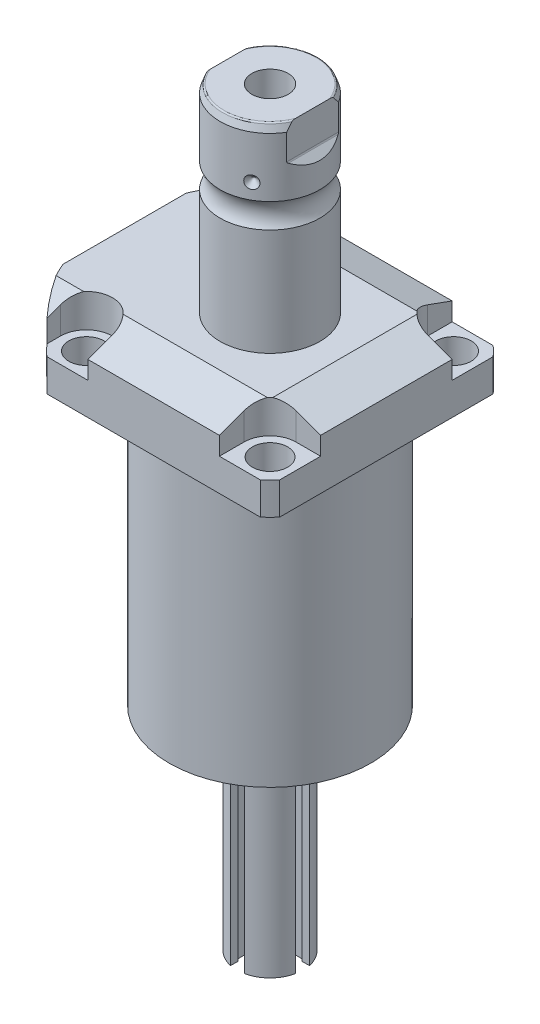
from build123d import *

# Parameters (mm, degrees)
SKETCH1_W                   = 88.9
SKETCH1_H                   = 99.9998
EXTRUDE1_DEPTH              = 129.794
SKETCH2_OUTSIDE_W           = 139.282
SKETCH2_OUTSIDE_H           = 128.182
SKETCH2_OUTSIDE_R           = 60.325
CUT_EXTRUDE1_DEPTH          = 130.794
SKETCH3_W                   = 38.1
SKETCH3_H                   = 104.775
FILLET1_R                   = 0.381
CUT_EXTRUDE2_DEPTH          = 12.7
CUT_EXTRUDE9_START          = -56.5498
CUT_EXTRUDE9_DEPTH          = 101.9998
CUT_EXTRUDE7_DEPTH          = 45.45
CUT_EXTRUDE7_DEPTH_BACK     = 45.45
SKETCH10_R                  = 1.1811
SKETCH11_R                  = 1.1811
CUT_EXTRUDE8_DEPTH          = 53.34
SKETCH17_W                  = 6.7437
SKETCH17_H                  = 12.319
HOLE1_AT_2_COUNT            = 2
HOLE1_AT_2_PITCH            = 70.104
HOLE1_AT_3_COUNT            = 2
HOLE1_AT_3_PITCH            = 99.142027577
HOLE1_AT_4_COUNT            = 2
HOLE1_AT_4_PITCH            = 70.104
CHAMFER1_SIZE               = 0.635
FILLET2_R                   = 0.635
CIRPATTERN1_COUNT           = 3
SKETCH24_R                  = 1.7272
CUT_EXTRUDE10_DEPTH         = 2.54
SKETCH25_R                  = 2.7051
EXTRUDE2_DEPTH              = 2.9464
CUT_EXTRUDE11_DEPTH         = 6.477
SKETCH32_W                  = 6.985
SKETCH32_H                  = 70.612
CUT_EXTRUDE12_DEPTH         = 3.302
CUT_EXTRUDE13_DEPTH         = 2.032
CIRPATTERN2_COUNT           = 2
CIRPATTERN2_ANGLE           = 90
CIRPATTERN2_COPY_1_DEPTH    = 6.477
CIRPATTERN2_COPY_2_SKETCH_W = 6.985
CIRPATTERN2_COPY_2_SKETCH_H = 70.612
CIRPATTERN2_COPY_2_DEPTH    = 3.302


with BuildPart() as part:
    # Sketch1 → Extrude1 (new body)
    with BuildSketch(Plane.ZX):
        with Locations((0, -5.5499)):
            Rectangle(SKETCH1_W, SKETCH1_H)
    extrude(amount=EXTRUDE1_DEPTH)

    # Sketch2 outside → Cut-Extrude1 (cut, through all)
    with BuildSketch(Plane.XZ):
        with Locations((-5.55, 0)):
            Rectangle(SKETCH2_OUTSIDE_W, SKETCH2_OUTSIDE_H)
        Circle(SKETCH2_OUTSIDE_R, mode=Mode.SUBTRACT)
    extrude(amount=-CUT_EXTRUDE1_DEPTH, mode=Mode.SUBTRACT)

    # Sketch3 → Cut-Revolve1 (revolve, cut)
    with BuildSketch(Plane(origin=(0, 0, 0), x_dir=(0, 0, 1), z_dir=(1, 0, 0))):
        with Locations((57.5437, -52.3875)):
            Rectangle(SKETCH3_W, SKETCH3_H)
    revolve(axis=Axis((0, 93.345, 0), (0, -1, 0)), mode=Mode.SUBTRACT)

    # Fillet1
    fillet1_edges = [part.edges().sort_by_distance(p)[0] for p in [
        (0, 104.775, -38.4937),
    ]]
    fillet(fillet1_edges, radius=FILLET1_R)

    # Sketch4 → Cut-Extrude2 (cut)
    with BuildSketch(Plane(origin=(0, 129.794, 0), x_dir=(-1, 0, 0), z_dir=(0, 1, 0))):
        with BuildLine():
            Line((-25.1206, -44.45), (-25.1206, -35.052))
            ThreePointArc((-25.1206, -35.052), (-28.029439713, -28.029439713), (-35.052, -25.1206))
            Line((-35.052, -25.1206), (-44.45, -25.1206))
            Line((-44.45, -25.1206), (-44.45, -44.45))
            Line((-44.45, -44.45), (-25.1206, -44.45))
        make_face()
        with BuildLine():
            Line((44.9834, -44.45), (25.1206, -44.45))
            Line((25.1206, -44.45), (25.1206, -35.052))
            ThreePointArc((25.1206, -35.052), (35.052, -25.1206), (44.9834, -35.052))
            Line((44.9834, -35.052), (44.9834, -44.45))
        make_face()
        with BuildLine():
            Line((25.1206, 44.45), (25.1206, 35.052))
            ThreePointArc((25.1206, 35.052), (35.052, 25.1206), (44.9834, 35.052))
            Line((44.9834, 35.052), (44.9834, 44.45))
            Line((44.9834, 44.45), (25.1206, 44.45))
        make_face()
        with BuildLine():
            Line((-35.052, 25.1206), (-44.45, 25.1206))
            Line((-44.45, 25.1206), (-44.45, 44.45))
            Line((-44.45, 44.45), (-25.1206, 44.45))
            Line((-25.1206, 44.45), (-25.1206, 35.052))
            ThreePointArc((-25.1206, 35.052), (-28.029439713, 28.029439713), (-35.052, 25.1206))
        make_face()
    extrude(amount=-CUT_EXTRUDE2_DEPTH, mode=Mode.SUBTRACT)

    # Sketch5 → Cut-Extrude9 (cut)
    with BuildSketch(Plane(origin=(0, 0, 0), x_dir=(0, 0, -1), z_dir=(1, 0, 0)).offset(CUT_EXTRUDE9_START)):
        Polygon((-28.575, 129.794), (-44.45, 124.015972531), (-44.45, 129.794), align=None)
    cut_extrude9 = extrude(amount=CUT_EXTRUDE9_DEPTH, mode=Mode.SUBTRACT)

    # Mirror1: Cut-Extrude9 across plane
    add(cut_extrude9.mirror(Plane.XY), mode=Mode.SUBTRACT)

    # Sketch9 → Cut-Extrude7 (cut, two sides)
    with BuildSketch(Plane.XY) as cut_extrude7_sk:
        Polygon((28.575, 129.794), (44.45, 124.015972531), (44.45, 129.794), align=None)
    extrude(amount=CUT_EXTRUDE7_DEPTH, mode=Mode.SUBTRACT)
    extrude(cut_extrude7_sk.sketch, amount=-CUT_EXTRUDE7_DEPTH_BACK, mode=Mode.SUBTRACT)

    # Sketch20 → Cut-Revolve4 (revolve, cut)
    with BuildSketch(Plane(origin=(-41.402, 88.9, -18.1102), x_dir=(0, 1, 0), z_dir=(1, 0, 0)), mode=Mode.PRIVATE) as cut_revolve4_sk:
        Polygon((15.875, 41.9227), (17.3228, 41.9227), (17.3228, 39.4716), (18.3388, 39.4716), (18.3388, 37.465), (29.3116, 37.465), (29.3116, 36.2204), (15.875, 36.2204), align=None)
    cut_revolve4 = revolve(cut_revolve4_sk.sketch.rotate(Axis((-41.402, 81.620304954, 18.1102), (0, 1, 0)), 180), axis=Axis((-41.402, 81.620304954, 18.1102), (0, 1, 0)), mode=Mode.SUBTRACT)  # turned: the seam where the file's is

    # Mirror10: Cut-Revolve4 across plane
    add(cut_revolve4.mirror(Plane.XY), mode=Mode.SUBTRACT)

    # S2D0007 → Cut-Revolve2 (revolve, cut)
    with BuildSketch(Plane(origin=(-55.5498, 101.9048, 12.9794), x_dir=(0, 1, 0), z_dir=(0, 0, 1)), mode=Mode.PRIVATE) as cut_revolve2_sk:
        Polygon((15.875, 0), (26.3525, 0), (26.3525, -0.254), (22.0599, -0.254), (21.517306865, -2.8067), (20.8534, -3.470606865), (20.8534, -14.224), (15.875, -14.224), align=None)
    revolve(cut_revolve2_sk.sketch.rotate(Axis((944.4502, 117.7798, 12.9794), (-1, 0, 0)), 90), axis=Axis((944.4502, 117.7798, 12.9794), (-1, 0, 0)), mode=Mode.SUBTRACT)  # turned: the seam where the file's is

    # Sketch13 → Cut-Revolve3 (revolve, cut)
    with BuildSketch(Plane(origin=(-55.5498, 101.9048, -12.9794), x_dir=(0, 1, 0), z_dir=(0, 0, 1)), mode=Mode.PRIVATE) as cut_revolve3_sk:
        Polygon((15.875, 0), (26.3525, 0), (26.3525, -0.254), (22.0599, -0.254), (21.517306865, -2.8067), (20.8534, -3.470606865), (20.8534, -14.224), (15.875, -14.224), align=None)
    revolve(cut_revolve3_sk.sketch.rotate(Axis((944.4502, 117.7798, -12.9794), (-1, 0, 0)), 90), axis=Axis((944.4502, 117.7798, -12.9794), (-1, 0, 0)), mode=Mode.SUBTRACT)  # turned: the seam where the file's is

    # Sketch15 → Revolve3 (revolve)
    with BuildSketch(Plane(origin=(0, 0, 0), x_dir=(0, -1, 0), z_dir=(1, 0, 0)), mode=Mode.PRIVATE) as revolve3_sk:
        with BuildLine():
            Line((-129.794, 0), (-129.794, 19.05))
            Line((-129.794, 19.05), (-170.57830643, 19.05))
            ThreePointArc((-170.57830643, 19.05), (-175.2854, 17.5006), (-179.99249357, 19.05))
            Line((-179.99249357, 19.05), (-202.5396, 19.05))
            Line((-202.5396, 19.05), (-205.4606, 17.986842946))
            Line((-205.4606, 17.986842946), (-205.4606, 0))
            Line((-205.4606, 0), (-129.794, 0))
        make_face()
    revolve(revolve3_sk.sketch.rotate(Axis((0, 197.63613, 0), (0, -1, 0)), 180), axis=Axis((0, 197.63613, 0), (0, -1, 0)))  # turned: the seam where the file's is

    # Sketch16 → Cut-Extrude8 (cut, symmetric)
    with BuildSketch(Plane(origin=(0, 0, 0), x_dir=(0, -1, 0), z_dir=(0, 0, -1))):
        with BuildLine():
            Line((-205.4606, 19.05), (-189.676369265, 19.05))
            Line((-189.676369265, 19.05), (-192.221784633, 16.504584633))
            ThreePointArc((-192.221784633, 16.504584633), (-192.468995225, 16.339403796), (-192.7606, 16.2814))
            Line((-192.7606, 16.2814), (-205.4606, 16.2814))
            Line((-205.4606, 16.2814), (-205.4606, 19.05))
        make_face()
        with BuildLine():
            Line((-205.4606, -19.05), (-205.4606, -16.2814))
            Line((-205.4606, -16.2814), (-192.7606, -16.2814))
            ThreePointArc((-192.7606, -16.2814), (-192.468995225, -16.339403796), (-192.221784633, -16.504584633))
            Line((-192.221784633, -16.504584633), (-189.676369265, -19.05))
            Line((-189.676369265, -19.05), (-205.4606, -19.05))
        make_face()
    extrude(amount=CUT_EXTRUDE8_DEPTH, both=True, mode=Mode.SUBTRACT)

    # Sketch17 → Hole1 (revolve, cut)
    with BuildSketch(Plane(origin=(35.052, 117.094, -35.052), x_dir=(0, 0, 1), z_dir=(1, 0, 0))):
        with Locations((3.37185, 6.1595)):
            Rectangle(SKETCH17_W, SKETCH17_H)
    hole1 = revolve(axis=Axis((35.052, 7.094, -35.052), (0, 1, 0)), mode=Mode.SUBTRACT)

    # Hole1 at 2: Hole1 ×2
    with Locations(*[(0, 0, i * HOLE1_AT_2_PITCH) for i in range(1, HOLE1_AT_2_COUNT)]):
        add(hole1, mode=Mode.SUBTRACT)

    # Hole1 at 3: Hole1 ×2
    with Locations(*[Vector(-0.707106781, 0, 0.707106781) * (i * HOLE1_AT_3_PITCH) for i in range(1, HOLE1_AT_3_COUNT)]):
        add(hole1, mode=Mode.SUBTRACT)

    # Hole1 at 4: Hole1 ×2
    with Locations(*[(-i * HOLE1_AT_4_PITCH, 0, 0) for i in range(1, HOLE1_AT_4_COUNT)]):
        add(hole1, mode=Mode.SUBTRACT)

    # Chamfer1
    chamfer1_edges = [part.edges().sort_by_distance(p)[0] for p in [
        (-41.402, 107.2388, 19.3548),
        (-41.402, 107.2388, -19.3548),
    ]]
    chamfer(chamfer1_edges, length=CHAMFER1_SIZE)

    # Sketch21 → Cut-Revolve5 (revolve, cut)
    with BuildSketch(Plane.XY, mode=Mode.PRIVATE) as cut_revolve5_sk:
        Polygon((0, 180.0606), (6.9342, 184.227087704), (6.9342, 205.4606), (0, 205.4606), align=None)
    revolve(cut_revolve5_sk.sketch.rotate(Axis((0, 0, 0), (0, 1, 0)), 270), axis=Axis((0, 0, 0), (0, 1, 0)), mode=Mode.SUBTRACT)  # turned: the seam where the file's is

    # Fillet2
    fillet2_edges = [part.edges().sort_by_distance(p)[0] for p in [
        (0, 205.4606, 17.986842946),
        (0, 205.4606, -17.986842946),
    ]]
    fillet(fillet2_edges, radius=FILLET2_R)

    # Sketch22 → Cut-Revolve6 (revolve, cut)
    with BuildSketch(Plane.XY, mode=Mode.PRIVATE) as cut_revolve6_sk:
        Polygon((-19.05, 188.3664), (-16.637, 185.9534), (-19.05, 185.9534), align=None)
    cut_revolve6 = revolve(cut_revolve6_sk.sketch.rotate(Axis((-37.997376206, 185.9534, 0), (1, 0, 0)), 90), axis=Axis((-37.997376206, 185.9534, 0), (1, 0, 0)), mode=Mode.SUBTRACT)  # turned: the seam where the file's is

    # CirPattern1: Cut-Revolve6 ×3 about axis
    cirpattern1_axis = Axis((0, 197.63613, 0), (0, 1, 0))
    for i in range(1, CIRPATTERN1_COUNT):
        add(cut_revolve6.rotate(cirpattern1_axis, i * 360 / CIRPATTERN1_COUNT), mode=Mode.SUBTRACT)

    # Sketch23 → Revolve5 (revolve)
    with BuildSketch(Plane.XY, mode=Mode.PRIVATE) as revolve5_sk:
        Polygon((0, 0), (22.225, 0), (22.225, -2.54), (12.7, -2.54), (12.7, -81.28), (0, -81.28), align=None)
    revolve(revolve5_sk.sketch.rotate(Axis((0, -1000, 0), (0, 1, 0)), 270), axis=Axis((0, -1000, 0), (0, 1, 0)))  # turned: the seam where the file's is

    # Sketch24 → Cut-Extrude10 (cut)
    with BuildSketch(Plane.XZ.offset(2.54)):
        with Locations((19.431, 0)):
            Circle(SKETCH24_R)
        with Locations((16.827739621, 9.7155)):
            Circle(SKETCH24_R)
        with Locations((9.7155, 16.827739621)):
            Circle(SKETCH24_R)
        with Locations((0, 19.431)):
            Circle(SKETCH24_R)
        with Locations(Location((-9.7155, 16.827739621, 0), (0, 0, 270))):  # turned: the seam where the file's is
            Circle(SKETCH24_R)
        with Locations(Location((-16.827739621, 9.7155, 0), (0, 0, 270))):  # turned: the seam where the file's is
            Circle(SKETCH24_R)
        with Locations(Location((-19.431, 0, 0), (0, 0, 270))):  # turned: the seam where the file's is
            Circle(SKETCH24_R)
        with Locations((-16.827739621, -9.7155)):
            Circle(SKETCH24_R)
        with Locations((-9.7155, -16.827739621)):
            Circle(SKETCH24_R)
        with Locations(Location((0, -19.431, 0), (0, 0, 270))):  # turned: the seam where the file's is
            Circle(SKETCH24_R)
        with Locations(Location((9.7155, -16.827739621, 0), (0, 0, 270))):  # turned: the seam where the file's is
            Circle(SKETCH24_R)
        with Locations(Location((16.827739621, -9.7155, 0), (0, 0, 270))):  # turned: the seam where the file's is
            Circle(SKETCH24_R)
    extrude(amount=-CUT_EXTRUDE10_DEPTH, mode=Mode.SUBTRACT)

    # Sketch25 → Extrude2 (add)
    with BuildSketch(Plane.XZ.offset(2.54)):
        with Locations((19.431, 0)):
            Circle(SKETCH25_R)
        with Locations((-9.7155, 16.827739621)):
            Circle(SKETCH25_R)
        with Locations((-9.7155, -16.827739621)):
            Circle(SKETCH25_R)
    extrude(amount=EXTRUDE2_DEPTH)

    # Sketch31 → Cut-Extrude11 (cut)
    with BuildSketch(Plane(origin=(0, -41.91, 12.7), x_dir=(-1, 0, 0), z_dir=(0, 0, 1))):
        with BuildLine():
            Line((-2.6416, -28.957376248), (-2.6416, 39.37))
            Line((-2.6416, 39.37), (2.6416, 39.37))
            Line((2.6416, 39.37), (2.6416, -28.957376248))
            ThreePointArc((2.6416, -28.957376248), (0, -34.7345), (-2.6416, -28.957376248))
        make_face()
    cut_extrude11 = extrude(amount=-CUT_EXTRUDE11_DEPTH, mode=Mode.SUBTRACT)

    # Sketch32 → Cut-Extrude12 (cut)
    with BuildSketch(Plane.XY.offset(6.223)):
        with Locations((0, -45.974)):
            Rectangle(SKETCH32_W, SKETCH32_H)
    cut_extrude12 = extrude(amount=CUT_EXTRUDE12_DEPTH, mode=Mode.SUBTRACT)

    # Mirror11: Cut-Extrude11, Cut-Extrude12 across plane
    add(cut_extrude11.mirror(Plane.XY), mode=Mode.SUBTRACT)
    add(cut_extrude12.mirror(Plane.XY), mode=Mode.SUBTRACT)

    # Sketch35 → Cut-Extrude13 (cut)
    with BuildSketch(Plane.XZ.offset(5.4864)):
        Polygon((19.431, -1.43714029), (20.6756, -0.718570145), (20.6756, 0.718570145), (19.431, 1.43714029), (18.1864, 0.718570145), (18.1864, -0.718570145), align=None)
        Polygon((-9.255302101, 15.46627346), (-8.306336769, 16.545549612), (-8.766534668, 17.907015772), (-10.175697899, 18.189205782), (-11.124663231, 17.10992963), (-10.664465332, 15.748463469), align=None)
        Polygon((-9.7155, -18.264879911), (-8.4709, -17.546309766), (-8.4709, -16.109169476), (-9.7155, -15.390599331), (-10.9601, -16.109169476), (-10.9601, -17.546309766), align=None)
    extrude(amount=-CUT_EXTRUDE13_DEPTH, mode=Mode.SUBTRACT)

    # CirPattern2: Cut-Extrude11, Cut-Extrude12 ×2 about axis
    cirpattern2_axis = Axis((0, 0, 0), (0, -1, 0))
    add([cut_extrude11.rotate(cirpattern2_axis, i * CIRPATTERN2_ANGLE / (CIRPATTERN2_COUNT - 1)) for i in range(1, CIRPATTERN2_COUNT)], mode=Mode.SUBTRACT)
    add([cut_extrude12.rotate(cirpattern2_axis, i * CIRPATTERN2_ANGLE / (CIRPATTERN2_COUNT - 1)) for i in range(1, CIRPATTERN2_COUNT)], mode=Mode.SUBTRACT)

    # CirPattern2 copy 1 sketch → CirPattern2 copy 1 (cut)
    with BuildSketch(Plane(origin=(12.7, -41.91, 0), x_dir=(0, 0, -1), z_dir=(1, 0, 0))):
        with BuildLine():
            Line((-2.6416, 28.957376248), (-2.6416, -39.37))
            Line((-2.6416, -39.37), (2.6416, -39.37))
            Line((2.6416, -39.37), (2.6416, 28.957376248))
            ThreePointArc((2.6416, 28.957376248), (0, 34.7345), (-2.6416, 28.957376248))
        make_face()
    extrude(amount=-CIRPATTERN2_COPY_1_DEPTH, mode=Mode.SUBTRACT)

    # CirPattern2 copy 2 sketch → CirPattern2 copy 2 (cut)
    with BuildSketch(Plane(origin=(6.223, 0, 0), x_dir=(0, 0, 1), z_dir=(1, 0, 0))):
        with Locations((0, 45.974)):
            Rectangle(CIRPATTERN2_COPY_2_SKETCH_W, CIRPATTERN2_COPY_2_SKETCH_H)
    extrude(amount=CIRPATTERN2_COPY_2_DEPTH, mode=Mode.SUBTRACT)


with BuildPart() as body_2:
    # Sketch10 → Revolve4 (revolve)
    with BuildSketch(Plane(origin=(-41.402, 88.9, -18.1102), x_dir=(0, 1, 0), z_dir=(1, 0, 0))):
        with Locations((16.1417, 4.5212)):
            Circle(SKETCH10_R)
    revolve(axis=Axis((-41.402, 87.86749, -18.1102), (0, 1, 0)))


with BuildPart() as body_3:
    # Sketch11 → Revolve2 (revolve)
    with BuildSketch(Plane(origin=(-41.402, 88.9, 18.1102), x_dir=(0, 1, 0), z_dir=(1, 0, 0)), mode=Mode.PRIVATE) as revolve2_sk:
        with Locations((16.1417, 4.5212)):
            Circle(SKETCH11_R)
    revolve(revolve2_sk.sketch.rotate(Axis((-41.402, 87.86749, 18.1102), (0, 1, 0)), 180), axis=Axis((-41.402, 87.86749, 18.1102), (0, 1, 0)))  # turned: the seam where the file's is


solid = Compound([part.part, body_2.part, body_3.part])
